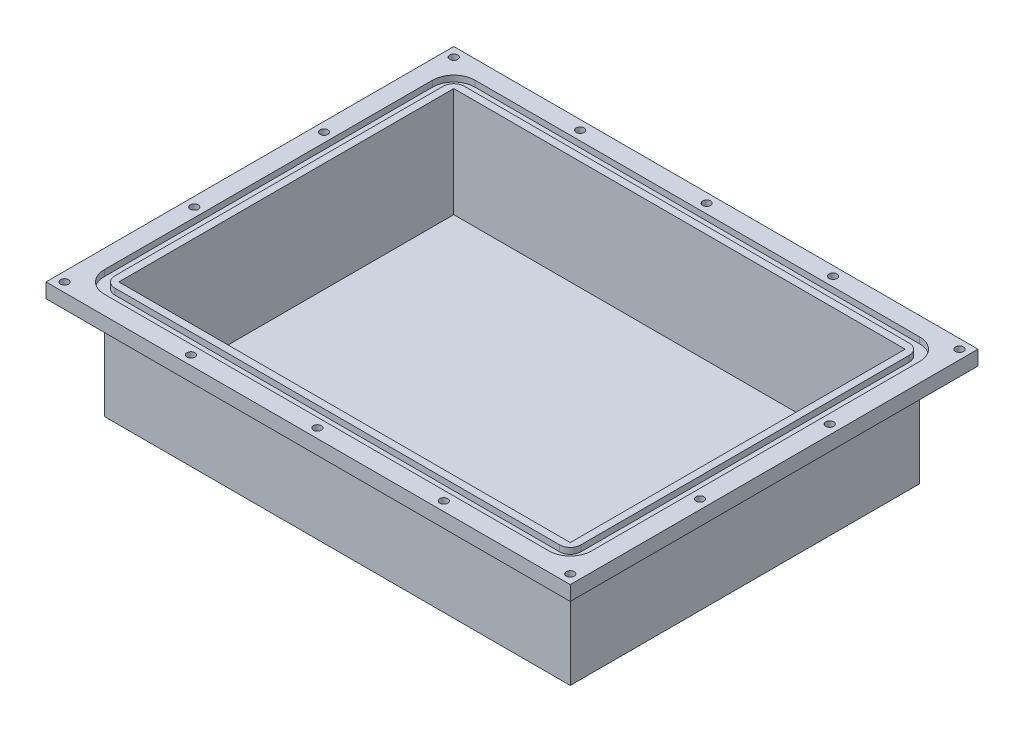
from build123d import *

# Parameters (mm, degrees)
SKETCH1_W             = 203.2
SKETCH1_H             = 152.4
BOSS_EXTRUDE1_DEPTH   = 50.8
SKETCH2_W             = 196.85
SKETCH2_H             = 146.05
CUT_EXTRUDE1_DEPTH    = 47.625
SKETCH4_W             = 228.6
SKETCH4_H             = 177.8
SKETCH4_W_2           = 203.2
SKETCH4_H_2           = 152.4
BOSS_EXTRUDE2_DEPTH   = 6.35
SKETCH7_W             = 212.4456
SKETCH7_H             = 161.6456
SKETCH7_W_2           = 203.2
SKETCH7_H_2           = 152.4
CUT_EXTRUDE2_DEPTH    = 2.6416
F_8_32_TAPPED_HOLE1_D = 3.4544
FILLET3_R             = 4.6228
FILLET4_R             = 9.2456


with BuildPart() as part:
    # Sketch1 → Boss-Extrude1 (new body)
    with BuildSketch(Plane(origin=(0, 0, 0), x_dir=(1, 0, 0), z_dir=(0, 1, 0))):
        Rectangle(SKETCH1_W, SKETCH1_H)
    extrude(amount=BOSS_EXTRUDE1_DEPTH)

    # Sketch2 → Cut-Extrude1 (cut)
    with BuildSketch(Plane(origin=(0, 50.8, 0), x_dir=(1, 0, 0), z_dir=(0, 1, 0))):
        Rectangle(SKETCH2_W, SKETCH2_H)
    extrude(amount=-CUT_EXTRUDE1_DEPTH, mode=Mode.SUBTRACT)

    # Sketch4 → Boss-Extrude2 (add)
    with BuildSketch(Plane(origin=(0, 50.8, 0), x_dir=(1, 0, 0), z_dir=(0, 1, 0))):
        Rectangle(SKETCH4_W, SKETCH4_H)
        Rectangle(SKETCH4_W_2, SKETCH4_H_2, mode=Mode.SUBTRACT)
    extrude(amount=-BOSS_EXTRUDE2_DEPTH)

    # Sketch7 → Cut-Extrude2 (cut)
    with BuildSketch(Plane(origin=(0, 50.8, 0), x_dir=(1, 0, 0), z_dir=(0, 1, 0))):
        Rectangle(SKETCH7_W, SKETCH7_H)
        Rectangle(SKETCH7_W_2, SKETCH7_H_2, mode=Mode.SUBTRACT)
    extrude(amount=-CUT_EXTRUDE2_DEPTH, mode=Mode.SUBTRACT)

    # #8-32 Tapped Hole1 (through all)
    with Locations(Plane(origin=(0, 50.8, 0), x_dir=(1, 0, 0), z_dir=(0, 1, 0))):
        with Locations((55.1307, 84.8614), (110.2614, 84.8614), (110.2614, 28.287133333), (0, 84.8614), (110.2614, -28.287133333), (110.2614, -84.8614), (55.1307, -84.8614), (0, -84.8614), (-55.1307, -84.8614), (-110.2614, -84.8614), (-110.2614, -28.287133333), (-110.2614, 28.287133333), (-110.2614, 84.8614), (-55.1307, 84.8614)):
            Hole(F_8_32_TAPPED_HOLE1_D / 2)

    # Fillet3
    fillet3_edges = [part.edges().sort_by_distance(p)[0] for p in [
        (-101.6, 49.4792, -76.2),
        (101.6, 49.4792, -76.2),
        (101.6, 49.4792, 76.2),
        (-101.6, 49.4792, 76.2),
    ]]
    fillet(fillet3_edges, radius=FILLET3_R)

    # Fillet4
    fillet4_edges = [part.edges().sort_by_distance(p)[0] for p in [
        (-106.2228, 49.4792, -80.8228),
        (106.2228, 49.4792, -80.8228),
        (106.2228, 49.4792, 80.8228),
        (-106.2228, 49.4792, 80.8228),
    ]]
    fillet(fillet4_edges, radius=FILLET4_R)


solid = part.part
